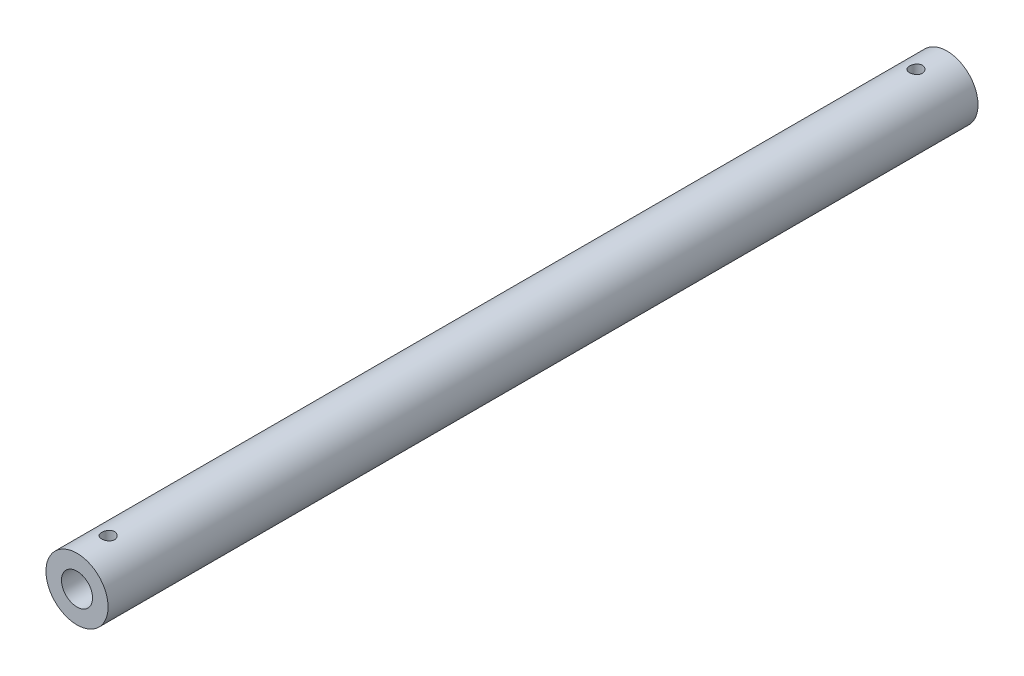
from build123d import *

# Parameters (mm, degrees)
BOSS_EXTRUDE1_DEPTH      = 210
BOSS_EXTRUDE1_DEPTH_BACK = 210
SKETCH1_R                = 15
SKETCH1_R_2              = 7.5
SKETCH3_R                = 3.1
CUT_EXTRUDE1_DEPTH       = 30


with BuildPart() as part:
    # Sketch1 → Boss-Extrude1 (new, two sides: drawn at the far end of the back side and taken through both)
    with BuildSketch(Plane.XY.offset(-BOSS_EXTRUDE1_DEPTH_BACK)):
        Circle(SKETCH1_R)
        Circle(SKETCH1_R_2, mode=Mode.SUBTRACT)
    extrude(amount=BOSS_EXTRUDE1_DEPTH + BOSS_EXTRUDE1_DEPTH_BACK)

    # Sketch3 → Cut-Extrude1 (cut)
    with BuildSketch(Plane(origin=(0, 0, 0), x_dir=(1, 0, 0), z_dir=(0, 1, 0))):
        with Locations((0, 195)):
            Circle(SKETCH3_R)
    cut_extrude1 = extrude(amount=CUT_EXTRUDE1_DEPTH, mode=Mode.SUBTRACT)

    # Mirror1: Cut-Extrude1 across plane
    add(cut_extrude1.mirror(Plane.XY), mode=Mode.SUBTRACT)


solid = part.part
